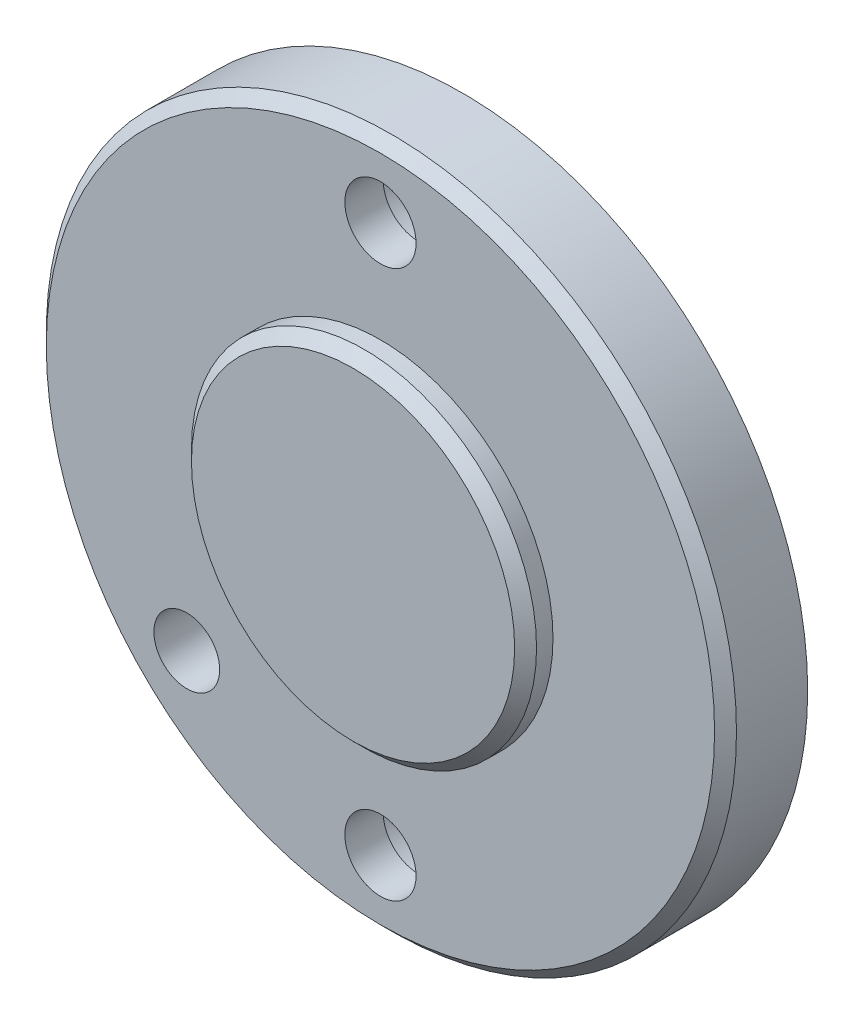
from build123d import *

# Parameters (mm, degrees)
SKETCH_1_R          = 31.5
EXTRUDE_1_DEPTH     = 7.5
SKETCH_2_R          = 15.75
EXTRUDE_2_DEPTH     = 2.5
CHAMFER_1_SIZE      = 1
CHAMFER_2_SIZE      = 1
SKETCH_3_R          = 3.25
SKETCH_3_R_2        = 3
CUT_EXTRUDE_1_DEPTH = 6.5
SKETCH_4_R          = 5.5
CUT_EXTRUDE_2_DEPTH = 4
SKETCH_9_R          = 15.75
EXTRUDE_5_DEPTH     = 5
SKETCH_10_W         = 1.475
SKETCH_10_H         = 34.619836182
SKETCH_12_W         = 34.390944704
SKETCH_12_H         = 1.475


with BuildPart() as part:
    # 草图1 → 凸台-拉伸1 (new body)
    with BuildSketch(Plane.XY):
        Circle(SKETCH_1_R)
    extrude(amount=EXTRUDE_1_DEPTH)

    # 草图2 → 凸台-拉伸2 (add)
    with BuildSketch(Plane.XY.offset(7.5)):
        Circle(SKETCH_2_R)
    extrude(amount=EXTRUDE_2_DEPTH)

    # 倒角1
    chamfer_1_edges = [part.edges().sort_by_distance(p)[0] for p in [
        (-15.75, 0, 10),
    ]]
    chamfer(chamfer_1_edges, length=CHAMFER_1_SIZE)

    # 倒角2
    chamfer_2_edges = [part.edges().sort_by_distance(p)[0] for p in [
        (-31.5, 0, 7.5),
    ]]
    chamfer(chamfer_2_edges, length=CHAMFER_2_SIZE)

    # 草图3 → 切除-拉伸1 (cut)
    with BuildSketch(Plane.XY.offset(7.5)):
        with Locations((0, 25)):
            Circle(SKETCH_3_R)
        with Locations((0, -25)):
            Circle(SKETCH_3_R)
        with Locations((-17.67766953, -17.67766953)):
            Circle(SKETCH_3_R_2)
    extrude(amount=-CUT_EXTRUDE_1_DEPTH, mode=Mode.SUBTRACT)

    # 草图4 → 切除-拉伸2 (cut)
    with BuildSketch(Plane(origin=(0, 0, 0), x_dir=(-1, 0, 0), z_dir=(0, 0, -1))):
        with Locations((0, -25)):
            Circle(SKETCH_4_R)
        with Locations((0, 25)):
            Circle(SKETCH_4_R)
    extrude(amount=-CUT_EXTRUDE_2_DEPTH, mode=Mode.SUBTRACT)

    # 草图9 → 凸台-拉伸5 (add)
    with BuildSketch(Plane(origin=(0, 0, 0), x_dir=(-1, 0, 0), z_dir=(0, 0, -1))):
        Circle(SKETCH_9_R)
    extrude(amount=EXTRUDE_5_DEPTH)

    # 草图10 → 切除-旋转1 (revolve, cut)
    with BuildSketch(Plane(origin=(0, 0, -2.5), x_dir=(-1, 0, 0), z_dir=(0, 0, -1))):
        with Locations((0.7375, 0.028611435)):
            Rectangle(SKETCH_10_W, SKETCH_10_H)
    revolve(axis=Axis((0, 17.338529526, -2.5), (0, -1, 0)), mode=Mode.SUBTRACT)

    # 草图12 → 切除-旋转2 (revolve, cut)
    with BuildSketch(Plane(origin=(0, 0, -2.5), x_dir=(-1, 0, 0), z_dir=(0, 0, -1))):
        with Locations((-0.028611435, 0.7375)):
            Rectangle(SKETCH_12_W, SKETCH_12_H)
    revolve(axis=Axis((17.224083787, 0, -2.5), (-1, 0, 0)), mode=Mode.SUBTRACT)


solid = part.part
